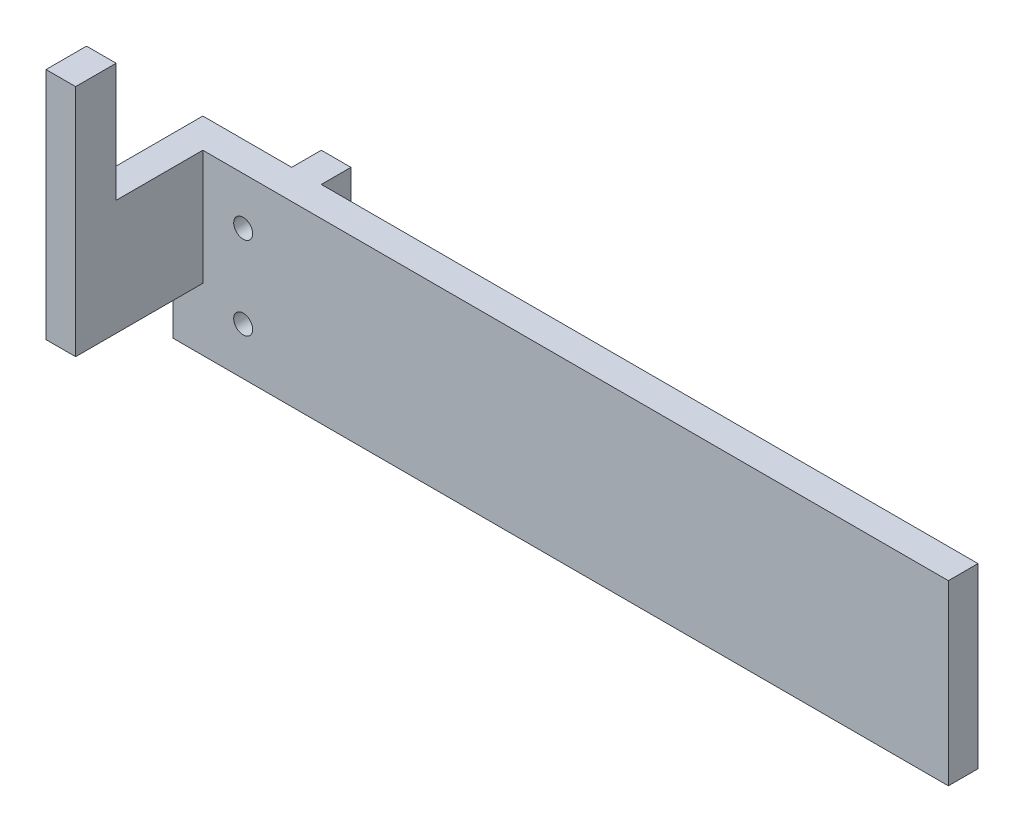
from build123d import *

# Parameters (mm, degrees)
SKETCH1_W                = 10
SKETCH1_H                = 30
BOSS_EXTRUDE1_DEPTH      = 5
SKETCH2_R                = 1.6
CUT_EXTRUDE2_DEPTH       = 43
SKETCH4_W                = 5
SKETCH4_H                = 30
BOSS_EXTRUDE2_DEPTH      = 5
BOSS_EXTRUDE2_DEPTH_BACK = 5
BOSS_EXTRUDE4_START      = -53
SKETCH6_W                = 5
SKETCH6_H                = 30
BOSS_EXTRUDE4_DEPTH      = 110.849702
SKETCH7_W                = 5
SKETCH7_H                = 30
BOSS_EXTRUDE5_DEPTH      = 26.472916
SKETCH8_W                = 5
SKETCH8_H                = 6.838689
BOSS_EXTRUDE6_DEPTH      = 20.03481
SKETCH9_W                = 5
SKETCH9_H                = 21.472916
CUT_EXTRUDE3_DEPTH       = 11.544021


with BuildPart() as part:
    # Sketch1 → Boss-Extrude1 (new body)
    with BuildSketch(Plane.XY):
        with Locations((5, -15)):
            Rectangle(SKETCH1_W, SKETCH1_H)
    extrude(amount=BOSS_EXTRUDE1_DEPTH)

    # Sketch2 → Cut-Extrude2 (cut)
    with BuildSketch(Plane(origin=(0, 0, 0), x_dir=(-1, 0, 0), z_dir=(0, 0, -1))):
        with Locations((-6.81031, -8)):
            Circle(SKETCH2_R)
        with Locations((-6.81031, -22)):
            Circle(SKETCH2_R)
    extrude(amount=-CUT_EXTRUDE2_DEPTH, mode=Mode.SUBTRACT)

    # Sketch4 → Boss-Extrude2 (add, two sides)
    with BuildSketch(Plane.XY) as boss_extrude2_sk:
        with Locations((12.5, -15)):
            Rectangle(SKETCH4_W, SKETCH4_H)
    extrude(amount=BOSS_EXTRUDE2_DEPTH)
    extrude(boss_extrude2_sk.sketch, amount=-BOSS_EXTRUDE2_DEPTH_BACK)

    # Sketch6 → Boss-Extrude4 (add)
    with BuildSketch(Plane.ZY.offset(-72.849702).offset(BOSS_EXTRUDE4_START)):
        with Locations((2.5, -15)):
            Rectangle(SKETCH6_W, SKETCH6_H)
    extrude(amount=BOSS_EXTRUDE4_DEPTH)

    # Sketch7 → Boss-Extrude5 (add)
    with BuildSketch(Plane(origin=(0, 0, 0), x_dir=(-1, 0, 0), z_dir=(0, 0, -1))):
        with Locations((2.5, -15)):
            Rectangle(SKETCH7_W, SKETCH7_H)
    extrude(amount=-BOSS_EXTRUDE5_DEPTH)

    # Sketch8 → Boss-Extrude6 (add)
    with BuildSketch(Plane(origin=(0, 0, 0), x_dir=(1, 0, 0), z_dir=(0, 1, 0))):
        with Locations((-2.5, -23.053571)):
            Rectangle(SKETCH8_W, SKETCH8_H)
    extrude(amount=BOSS_EXTRUDE6_DEPTH)

    # Sketch9 → Cut-Extrude3 (cut, through all)
    with BuildSketch(Plane.XZ.offset(19.455979)):
        with Locations((-2.5, 15.736458)):
            Rectangle(SKETCH9_W, SKETCH9_H)
    extrude(amount=CUT_EXTRUDE3_DEPTH, mode=Mode.SUBTRACT)


solid = part.part
